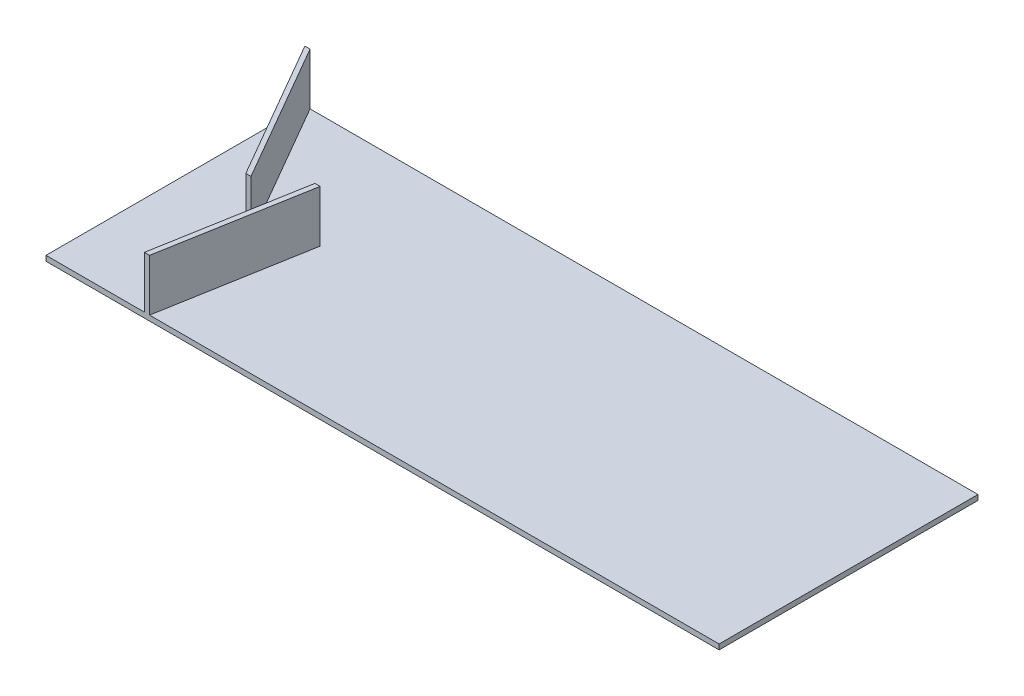
from build123d import *

# Parameters (mm, degrees)
SKETCH1_W           = 1300
SKETCH1_H           = 500
BOSS_EXTRUDE1_DEPTH = 10
BOSS_EXTRUDE3_DEPTH = 100


with BuildPart() as part:
    # Sketch1 → Boss-Extrude1 (new body)
    with BuildSketch(Plane(origin=(0, 0, 0), x_dir=(1, 0, 0), z_dir=(0, 1, 0))):
        with Locations((650, 0)):
            Rectangle(SKETCH1_W, SKETCH1_H)
    extrude(amount=BOSS_EXTRUDE1_DEPTH)

    # Sketch6 → Boss-Extrude3 (add)
    with BuildSketch(Plane(origin=(0, 10, 0), x_dir=(1, 0, 0), z_dir=(0, 1, 0))):
        Polygon((200, -250), (190, -250), (239.371554598, 30), (249.371554598, 30), align=None)
        Polygon((0, 250), (10, 250), (165.884572681, -20), (155.884572681, -20), align=None)
    extrude(amount=BOSS_EXTRUDE3_DEPTH)


solid = part.part
